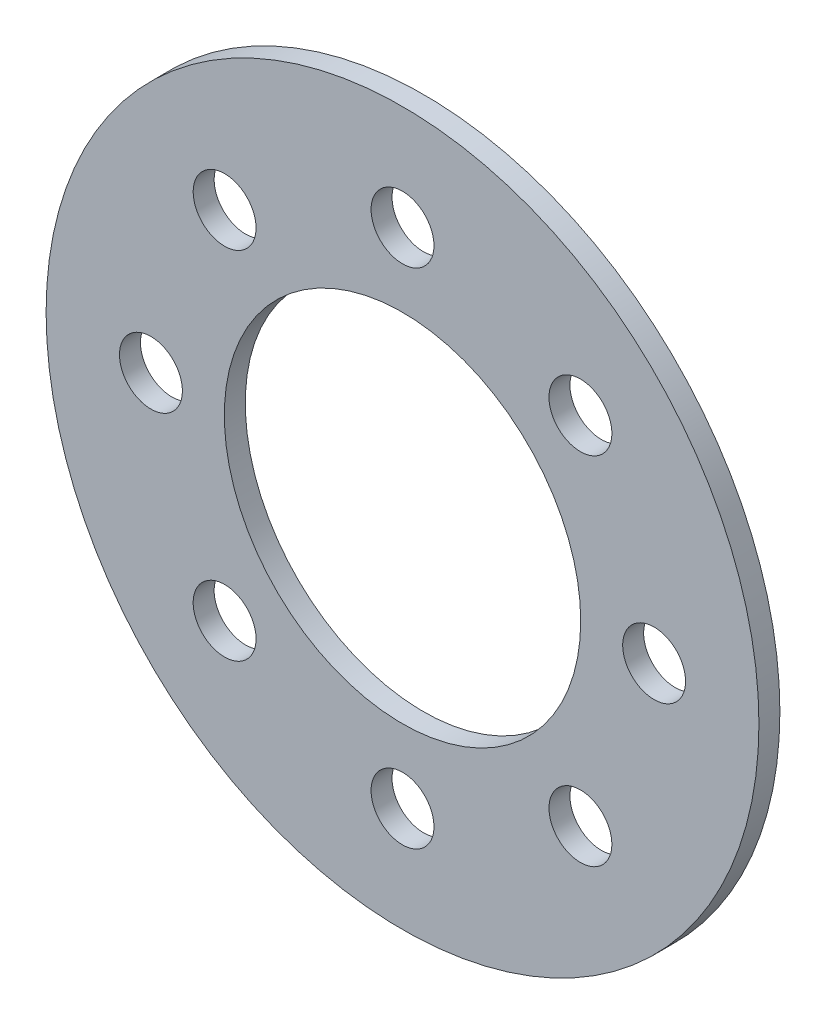
from build123d import *

# Parameters (mm, degrees)
SKETCH1_R           = 17
SKETCH1_R_2         = 8.5
BOSS_EXTRUDE1_DEPTH = 1
SKETCH2_R           = 1.5
CUT_EXTRUDE1_DEPTH  = 25.062418831
CIRPATTERN1_COUNT   = 8


with BuildPart() as part:
    # Sketch1 → Boss-Extrude1 (new body)
    with BuildSketch(Plane.XY):
        Circle(SKETCH1_R)
        Circle(SKETCH1_R_2, mode=Mode.SUBTRACT)
    extrude(amount=BOSS_EXTRUDE1_DEPTH)

    # Sketch2 → Cut-Extrude1 (cut, symmetric)
    with BuildSketch(Plane.XY.offset(1)):
        with Locations((0, 12)):
            Circle(SKETCH2_R)
    cut_extrude1 = extrude(amount=CUT_EXTRUDE1_DEPTH, both=True, mode=Mode.SUBTRACT)

    # CirPattern1: Cut-Extrude1 ×8 about axis
    cirpattern1_axis = Axis((0, 0, 1), (0, 0, -1))
    for i in range(1, CIRPATTERN1_COUNT):
        add(cut_extrude1.rotate(cirpattern1_axis, i * 360 / CIRPATTERN1_COUNT), mode=Mode.SUBTRACT)


solid = part.part
